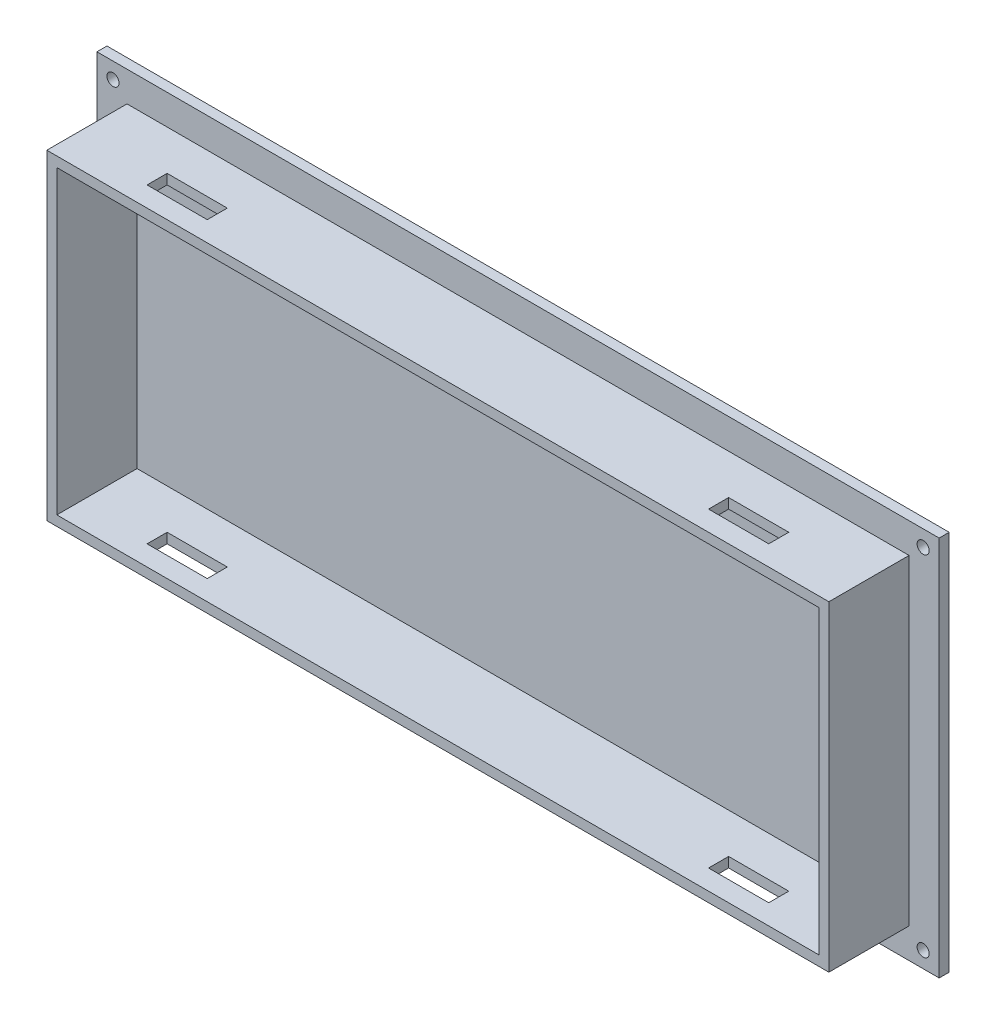
from build123d import *

# Parameters (mm, degrees)
SKETCH1_W           = 210
SKETCH1_H           = 95
BOSS_EXTRUDE1_DEPTH = 2.5
SKETCH2_W           = 195
SKETCH2_H           = 80
BOSS_EXTRUDE2_DEPTH = 20
SKETCH3_W           = 190
SKETCH3_H           = 75
CUT_EXTRUDE1_DEPTH  = 20
SKETCH5_W           = 15
SKETCH5_H           = 5
CUT_EXTRUDE3_DEPTH  = 80
SKETCH6_R           = 1.5
CUT_EXTRUDE4_DEPTH  = 2.5


with BuildPart() as part:
    # Sketch1 → Boss-Extrude1 (new body)
    with BuildSketch(Plane.XY):
        with Locations((105, 47.5)):
            Rectangle(SKETCH1_W, SKETCH1_H)
    extrude(amount=BOSS_EXTRUDE1_DEPTH)

    # Sketch2 → Boss-Extrude2 (add)
    with BuildSketch(Plane.XY.offset(2.5)):
        with Locations((105, 47.5)):
            Rectangle(SKETCH2_W, SKETCH2_H)
    extrude(amount=BOSS_EXTRUDE2_DEPTH)

    # Sketch3 → Cut-Extrude1 (cut)
    with BuildSketch(Plane.XY.offset(22.5)):
        with Locations((105, 47.5)):
            Rectangle(SKETCH3_W, SKETCH3_H)
    extrude(amount=-CUT_EXTRUDE1_DEPTH, mode=Mode.SUBTRACT)

    # Sketch5 → Cut-Extrude3 (cut)
    with BuildSketch(Plane(origin=(0, 87.5, 0), x_dir=(1, 0, 0), z_dir=(0, 1, 0))):
        with Locations((175, -15)):
            Rectangle(SKETCH5_W, SKETCH5_H)
        with Locations((35, -15)):
            Rectangle(SKETCH5_W, SKETCH5_H)
    extrude(amount=-CUT_EXTRUDE3_DEPTH, mode=Mode.SUBTRACT)

    # Sketch6 → Cut-Extrude4 (cut)
    with BuildSketch(Plane.XY.offset(2.5)):
        with Locations((4, 91)):
            Circle(SKETCH6_R)
        with Locations((206, 91)):
            Circle(SKETCH6_R)
        with Locations((206, 4)):
            Circle(SKETCH6_R)
        with Locations((4, 4)):
            Circle(SKETCH6_R)
    extrude(amount=-CUT_EXTRUDE4_DEPTH, mode=Mode.SUBTRACT)


solid = part.part
